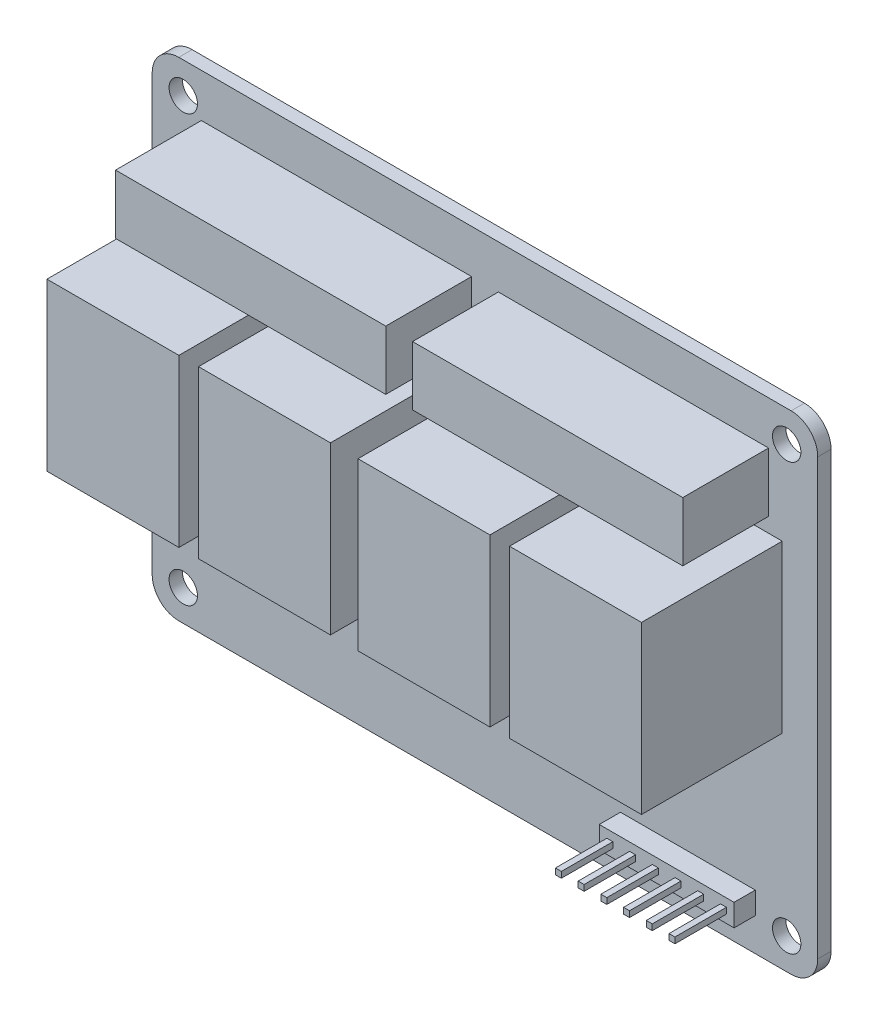
from build123d import *

# Parameters (mm, degrees)
CROQUIS1_W                   = 75
CROQUIS1_H                   = 55
SALIENTE_EXTRUIR1_DEPTH      = 1.5
REDONDEO1_R                  = 3
TALADRO_DE_MARGEN_PARA_M31_D = 3.2
CROQUIS4_W                   = 14.87
CROQUIS4_H                   = 18.75
SALIENTE_EXTRUIR2_DEPTH      = 15.86
CROQUIS5_W                   = 30.45
CROQUIS5_H                   = 6.67
SALIENTE_EXTRUIR3_DEPTH      = 9.67
CROQUIS6_W                   = 15.19
CROQUIS6_H                   = 2.5
SALIENTE_EXTRUIR4_DEPTH      = 2.39
CROQUIS7_W                   = 0.67
CROQUIS7_H                   = 0.67
SALIENTE_EXTRUIR5_DEPTH      = 5.8


with BuildPart() as part:
    # Croquis1 → Saliente-Extruir1 (new body)
    with BuildSketch(Plane.XY):
        Rectangle(CROQUIS1_W, CROQUIS1_H)
    extrude(amount=SALIENTE_EXTRUIR1_DEPTH)

    # Redondeo1
    redondeo1_edges = [part.edges().sort_by_distance(p)[0] for p in [
        (-37.5, 27.5, 0.75),
        (37.5, 27.5, 0.75),
        (37.5, -27.5, 0.75),
        (-37.5, -27.5, 0.75),
    ]]
    fillet(redondeo1_edges, radius=REDONDEO1_R)

    # Taladro de margen para M31 (through all)
    with Locations(Plane.XY.offset(1.5)):
        with Locations((-34, 24), (-34, -24), (34, 24), (34, -24)):
            Hole(TALADRO_DE_MARGEN_PARA_M31_D / 2)

    # Croquis4 → Saliente-Extruir2 (add)
    with BuildSketch(Plane.XY.offset(1.5)):
        with Locations((-26.065, 4.905)):
            Rectangle(CROQUIS4_W, CROQUIS4_H)
        with Locations((-8.985, 4.905)):
            Rectangle(CROQUIS4_W, CROQUIS4_H)
        with Locations((8.985, 4.905)):
            Rectangle(CROQUIS4_W, CROQUIS4_H)
        with Locations((26.065, 4.905)):
            Rectangle(CROQUIS4_W, CROQUIS4_H)
    extrude(amount=SALIENTE_EXTRUIR2_DEPTH)

    # Croquis5 → Saliente-Extruir3 (add)
    with BuildSketch(Plane.XY.offset(1.5)):
        with Locations((-16.735, 19.265)):
            Rectangle(CROQUIS5_W, CROQUIS5_H)
        with Locations((16.735, 19.265)):
            Rectangle(CROQUIS5_W, CROQUIS5_H)
    extrude(amount=SALIENTE_EXTRUIR3_DEPTH)

    # Croquis6 → Saliente-Extruir4 (add)
    with BuildSketch(Plane.XY.offset(1.5)):
        with Locations((22.865, -22.54)):
            Rectangle(CROQUIS6_W, CROQUIS6_H)
    extrude(amount=SALIENTE_EXTRUIR4_DEPTH)

    # Croquis7 → Saliente-Extruir5 (add)
    with BuildSketch(Plane.XY.offset(3.89)):
        with Locations((16.465, -22.54)):
            Rectangle(CROQUIS7_W, CROQUIS7_H)
        with Locations((19.025, -22.54)):
            Rectangle(CROQUIS7_W, CROQUIS7_H)
        with Locations((21.585, -22.54)):
            Rectangle(CROQUIS7_W, CROQUIS7_H)
        with Locations((24.145, -22.54)):
            Rectangle(CROQUIS7_W, CROQUIS7_H)
        with Locations((26.705, -22.54)):
            Rectangle(CROQUIS7_W, CROQUIS7_H)
        with Locations((29.265, -22.54)):
            Rectangle(CROQUIS7_W, CROQUIS7_H)
    extrude(amount=SALIENTE_EXTRUIR5_DEPTH)


solid = part.part
